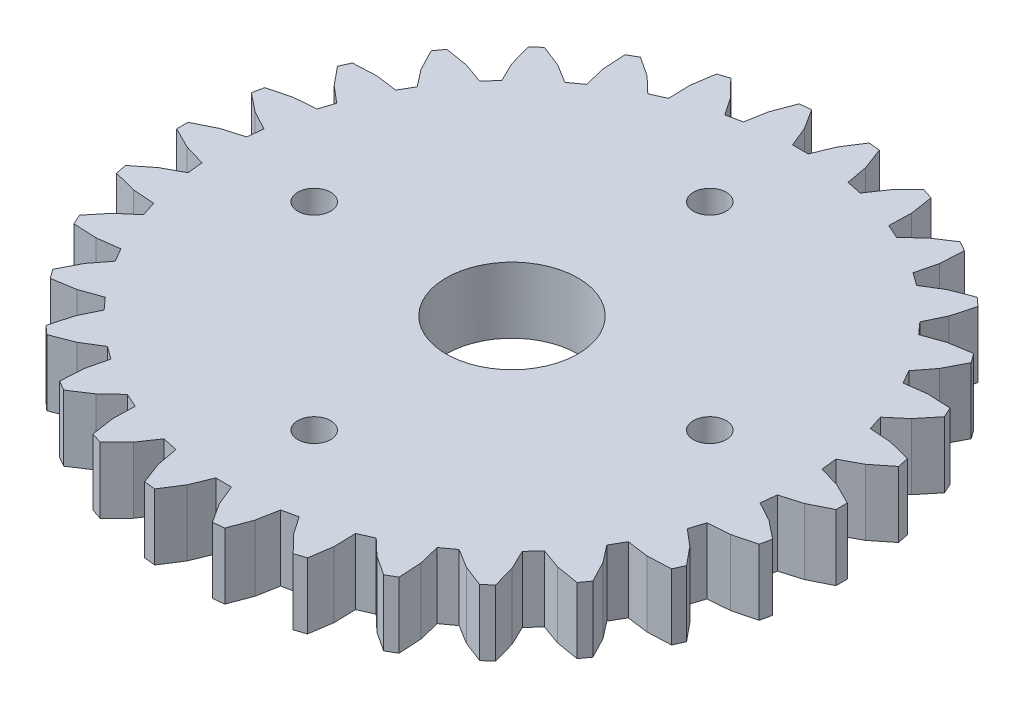
from build123d import *

# Parameters (mm, degrees)
BOSS_EXTRUDE1_DEPTH = 5
CUT_EXTRUDE1_REACH  = 115.767
SKETCH2_R           = 5
SKETCH2_R_2         = 1.25


with BuildPart() as part:
    # Sketch1 → Boss-Extrude1 (new body)
    with BuildSketch(Plane(origin=(0, 0, 0), x_dir=(1, 0, 0), z_dir=(0, 1, 0))):
        Polygon((67.838691437, 65.517866318), (69.4350027, 65.049749419), (71.026159174, 64.251961707), (71.026159174, 63.394033481), (69.4350027, 62.596245769), (67.838691437, 62.12812887), (67.714359377, 60.945685054), (69.178606177, 60.155998099), (70.569088563, 59.044741521), (70.390752331, 58.205591984), (68.668390309, 57.75600806), (67.009606199, 57.630080376), (66.642255801, 56.499308835), (67.91024703, 55.42254103), (69.039300308, 54.046418819), (68.690360246, 53.262746436), (66.912276224, 53.181003905), (65.263556413, 53.40278858), (64.669020401, 52.373151894), (65.685401977, 51.056188644), (66.503808846, 49.475342184), (65.999484477, 48.781390015), (64.243247317, 49.071170681), (62.676638392, 49.630849566), (61.881060372, 48.747269162), (62.601400993, 47.247796879), (63.073200133, 45.531449431), (62.435706672, 44.957410372), (60.778026756, 45.60595012), (59.362138343, 46.47909787), (58.400251933, 45.780236192), (58.793008793, 44.163795895), (58.89770325, 42.386816503), (58.154779059, 41.957852172), (56.668193967, 42.936921648), (55.464639564, 44.08536725), (54.378544169, 43.601785548), (54.426656842, 41.938950842), (54.159581951, 40.179154516), (53.343629619, 39.914043603), (52.093189812, 41.180807128), (51.154746322, 42.554351727), (49.99181747, 42.307160589), (49.693199773, 40.670591694), (49.066015892, 39.004811457), (48.21275146, 38.915090809), (47.252951668, 40.414194737), (46.620736072, 41.952820022), (45.431664484, 41.952820022), (44.799448453, 40.414194737), (43.839648661, 38.915090809), (42.986384664, 39.004811457), (42.359200783, 40.670591694), (42.060582651, 42.307160589), (40.897654234, 42.554351727), (39.959210744, 41.180807128), (38.708770937, 39.914043603), (37.89281817, 40.179154516), (37.625743714, 41.938950842), (37.673856387, 43.601785548), (36.587760557, 44.08536725), (35.384206154, 42.936921648), (33.897621497, 41.957852172), (33.154697306, 42.386816503), (33.259391328, 44.163795895), (33.652148188, 45.780236192), (32.690262213, 46.47909787), (31.274373365, 45.60595012), (29.616693883, 44.957410372), (28.979200423, 45.531449431), (29.450999563, 47.247796879), (30.171340183, 48.747269162), (29.375762164, 49.630849566), (27.809152804, 49.071170681), (26.052915644, 48.781390015), (25.548591275, 49.475342184), (26.366998579, 51.056188644), (27.38337972, 52.373151894), (26.788844143, 53.40278858), (25.140124332, 53.181003905), (23.362039875, 53.262746436), (23.013100248, 54.046418819), (24.142153526, 55.42254103), (25.410144754, 56.499308835), (25.042794357, 57.630080376), (23.384009811, 57.75600806), (21.661648225, 58.205591984), (21.483311993, 59.044741521), (22.873793943, 60.155998099), (24.338041179, 60.945685054), (24.213708684, 62.12812887), (22.617397421, 62.596245769), (21.026240947, 63.394033481), (21.026240947, 64.251961707), (22.617397421, 65.049749419), (24.213708684, 65.517866318), (24.338041179, 66.700310134), (22.873793943, 67.489997089), (21.483311993, 68.601253667), (21.661648225, 69.440403204), (23.384009811, 69.889987128), (25.042794357, 70.015914812), (25.410144754, 71.146686788), (24.142153526, 72.223454158), (23.013100248, 73.599576369), (23.362039875, 74.383249187), (25.140124332, 74.464991718), (26.788844143, 74.243206608), (27.38337972, 75.272843294), (26.366998579, 76.589806544), (25.548591275, 78.170653004), (26.052915644, 78.864605173), (27.809152804, 78.574824507), (29.375762164, 78.015145622), (30.171340183, 78.898726027), (29.450999563, 80.398198309), (28.979200423, 82.114546192), (29.616693883, 82.688584816), (31.274373365, 82.040045068), (32.690262213, 81.166897318), (33.652148188, 81.865758997), (33.259391328, 83.482199293), (33.154697306, 85.259178685), (33.897621497, 85.688143016), (35.384206154, 84.70907354), (36.587760557, 83.560627938), (37.673856387, 84.04420964), (37.625743714, 85.707044346), (37.89281817, 87.466840672), (38.708770937, 87.731951585), (39.959210744, 86.465188061), (40.897654234, 85.091643462), (42.060582651, 85.338834599), (42.359200783, 86.975403494), (42.986384664, 88.641183731), (43.839648661, 88.730904379), (44.799448453, 87.231800451), (45.431664484, 85.693175166), (46.620736072, 85.693175166), (47.252951668, 87.231800451), (48.21275146, 88.730904379), (49.066015892, 88.641183731), (49.693199773, 86.975403494), (49.99181747, 85.338834599), (51.154746322, 85.091643462), (52.093189812, 86.465188061), (53.343629619, 87.731951585), (54.159581951, 87.466840672), (54.426656842, 85.707044346), (54.378544169, 84.04420964), (55.464639564, 83.560627938), (56.668193967, 84.70907354), (58.154779059, 85.688143016), (58.89770325, 85.259178685), (58.793008793, 83.482199293), (58.400251933, 81.865758997), (59.362138343, 81.166897318), (60.778026756, 82.040045068), (62.435706672, 82.688584816), (63.073200133, 82.114546192), (62.601400993, 80.398198309), (61.881060372, 78.898726027), (62.676638392, 78.015145622), (64.243247317, 78.574824507), (65.999484477, 78.864605173), (66.503808846, 78.170653004), (65.685401977, 76.589806544), (64.669020401, 75.272843294), (65.263556413, 74.243206608), (66.912276224, 74.464991718), (68.690360246, 74.383249187), (69.039300308, 73.599576369), (67.91024703, 72.223454158), (66.642255801, 71.146686788), (67.009606199, 70.015914812), (68.668390309, 69.889987128), (70.390752331, 69.440403204), (70.569088563, 68.601253667), (69.178606177, 67.489997089), (67.714359377, 66.700310134), align=None)
    extrude(amount=BOSS_EXTRUDE1_DEPTH)

    # Sketch2 → Cut-Extrude1 (cut, up to next)
    with BuildSketch(Plane(origin=(0, 0, 0), x_dir=(1, 0, 0), z_dir=(0, 1, 0)), mode=Mode.PRIVATE) as cut_extrude1_sk1:
        with Locations((46.02620006, 63.822997594)):
            Circle(SKETCH2_R)
    cut_extrude1_tool1 = extrude(cut_extrude1_sk1.sketch, amount=CUT_EXTRUDE1_REACH, mode=Mode.PRIVATE) & part.part
    # Sketch2 → Cut-Extrude1 (cut, up to next)
    with BuildSketch(Plane(origin=(0, 0, 0), x_dir=(1, 0, 0), z_dir=(0, 1, 0)), mode=Mode.PRIVATE) as cut_extrude1_sk2:
        with Locations((31.02620006, 63.822997594)):
            Circle(SKETCH2_R_2)
    cut_extrude1_tool2 = extrude(cut_extrude1_sk2.sketch, amount=CUT_EXTRUDE1_REACH, mode=Mode.PRIVATE) & part.part
    # Sketch2 → Cut-Extrude1 (cut, up to next)
    with BuildSketch(Plane(origin=(0, 0, 0), x_dir=(1, 0, 0), z_dir=(0, 1, 0)), mode=Mode.PRIVATE) as cut_extrude1_sk3:
        with Locations((46.02620006, 78.822997594)):
            Circle(SKETCH2_R_2)
    cut_extrude1_tool3 = extrude(cut_extrude1_sk3.sketch, amount=CUT_EXTRUDE1_REACH, mode=Mode.PRIVATE) & part.part
    # Sketch2 → Cut-Extrude1 (cut, up to next)
    with BuildSketch(Plane(origin=(0, 0, 0), x_dir=(1, 0, 0), z_dir=(0, 1, 0)), mode=Mode.PRIVATE) as cut_extrude1_sk4:
        with Locations((61.02620006, 63.822997594)):
            Circle(SKETCH2_R_2)
    cut_extrude1_tool4 = extrude(cut_extrude1_sk4.sketch, amount=CUT_EXTRUDE1_REACH, mode=Mode.PRIVATE) & part.part
    # Sketch2 → Cut-Extrude1 (cut, up to next)
    with BuildSketch(Plane(origin=(0, 0, 0), x_dir=(1, 0, 0), z_dir=(0, 1, 0)), mode=Mode.PRIVATE) as cut_extrude1_sk5:
        with Locations((46.02620006, 48.822997594)):
            Circle(SKETCH2_R_2)
    cut_extrude1_tool5 = extrude(cut_extrude1_sk5.sketch, amount=CUT_EXTRUDE1_REACH, mode=Mode.PRIVATE) & part.part
    add(cut_extrude1_tool1.solids().sort_by_distance((46.0262, 0, -63.822998))[0], mode=Mode.SUBTRACT)
    add(cut_extrude1_tool2.solids().sort_by_distance((31.0262, 0, -63.822998))[0], mode=Mode.SUBTRACT)
    add(cut_extrude1_tool3.solids().sort_by_distance((46.0262, 0, -78.822998))[0], mode=Mode.SUBTRACT)
    add(cut_extrude1_tool4.solids().sort_by_distance((61.0262, 0, -63.822998))[0], mode=Mode.SUBTRACT)
    add(cut_extrude1_tool5.solids().sort_by_distance((46.0262, 0, -48.822998))[0], mode=Mode.SUBTRACT)


solid = part.part
